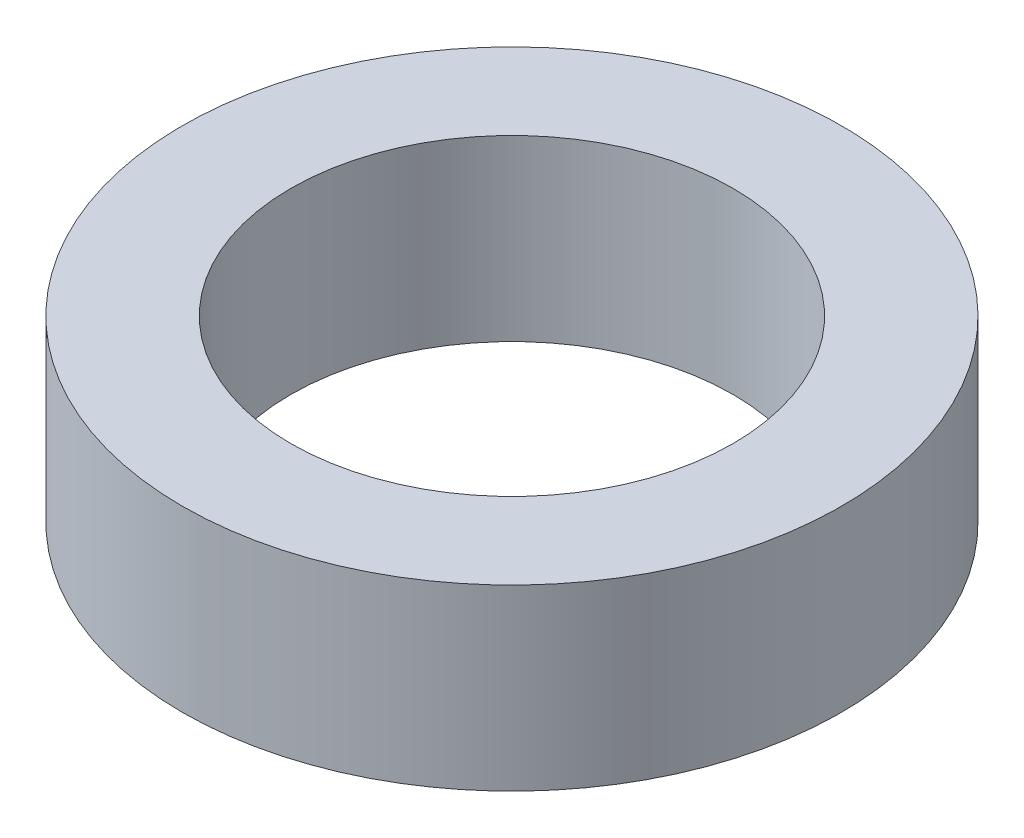
from build123d import *

# Parameters (mm, degrees)
SKETCH1_R           = 6
SKETCH1_R_2         = 4.025
BOSS_EXTRUDE1_DEPTH = 3.25


with BuildPart() as part:
    # Sketch1 → Boss-Extrude1 (new body)
    with BuildSketch(Plane(origin=(0, 0, 0), x_dir=(1, 0, 0), z_dir=(0, 1, 0))):
        Circle(SKETCH1_R)
        Circle(SKETCH1_R_2, mode=Mode.SUBTRACT)
    extrude(amount=BOSS_EXTRUDE1_DEPTH)


solid = part.part
